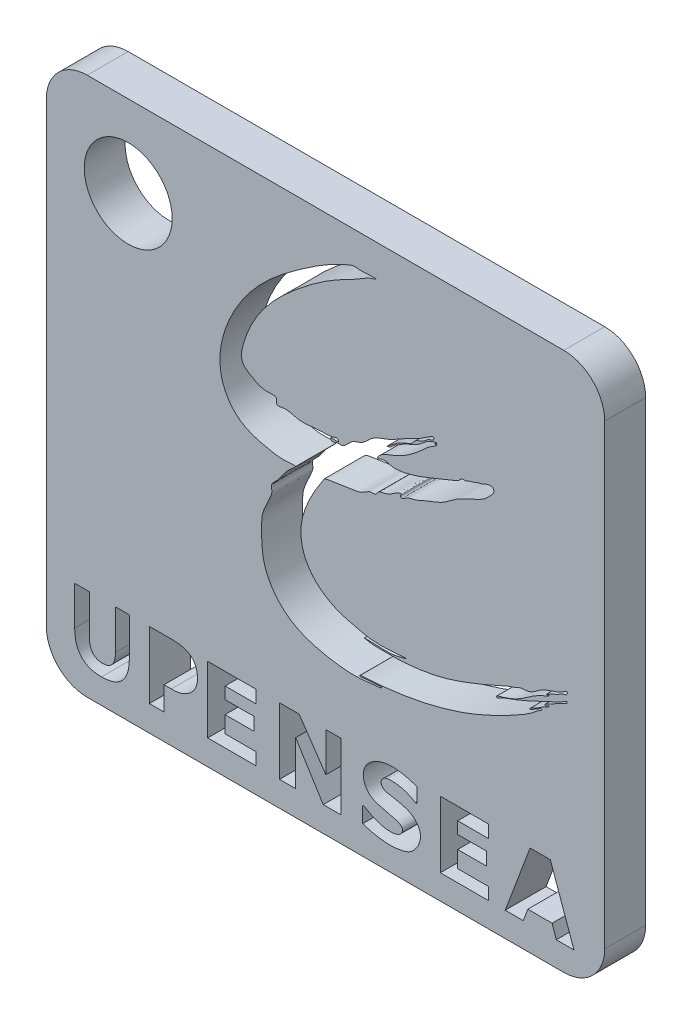
from build123d import *

# Parameters (mm, degrees)
ESQUISSE1_W             = 136.4195894
ESQUISSE1_H             = 131.62408288
ESQUISSE1_R             = 10.743118226
BOSS_EXTRU_1_DEPTH      = 10
CONG_1_R                = 10
ENL_V_MAT_EXTRU_1_DEPTH = 10
ESQUISSE3_W             = 7.085485745
ESQUISSE3_H             = 7.710675664
ENL_V_MAT_EXTRU_2_DEPTH = 10


with BuildPart() as part:
    # Esquisse1 → Boss.-Extru.1 (new body)
    with BuildSketch(Plane.XY):
        with Locations((-52.353656292, 10.654936195)):
            Rectangle(ESQUISSE1_W, ESQUISSE1_H)
        with Locations((-100.563450992, 56.466977635)):
            Circle(ESQUISSE1_R, mode=Mode.SUBTRACT)
        Polygon((-81.142119991, -32.834154765), (-69.373577812, -32.834154765), (-69.373577812, -35.9209855), (-76.89772773, -35.9209855), (-76.89772773, -38.814889315), (-69.867445854, -38.814889315), (-69.867445854, -41.991744615), (-76.89772773, -41.991744615), (-76.89772773, -46.050417687), (-69.373577812, -46.050417687), (-69.373577812, -49.040016126), (-81.142119991, -49.040016126), align=None, mode=Mode.SUBTRACT)
        Polygon((-63.602729459, -32.834154765), (-58.791958965, -32.834154765), (-52.26774974, -42.390122526), (-52.26774974, -32.834154765), (-48.574180783, -32.834154765), (-48.574180783, -49.040016126), (-52.913297725, -49.040016126), (-59.643973187, -38.236108552), (-59.643973187, -49.040016126), (-63.602729459, -49.040016126), align=None, mode=Mode.SUBTRACT)
        Polygon((-24.317493797, -32.949952007), (-12.548951618, -32.949952007), (-12.548951618, -36.036782743), (-20.073101536, -36.036782743), (-20.073101536, -38.930686557), (-13.04281966, -38.930686557), (-13.04281966, -42.107541857), (-20.073101536, -42.107541857), (-20.073101536, -46.16621493), (-12.548951618, -46.16621493), (-12.548951618, -49.155813369), (-24.317493797, -49.155813369), align=None, mode=Mode.SUBTRACT)
        Polygon((-2.380831571, -32.949952007), (-8.462013051, -49.155813369), (-4.055348693, -49.155813369), (-2.933514422, -46.16621493), (3.00425704, -46.16621493), (4.031172801, -49.155813369), (8.341293256, -49.155813369), (2.56810439, -32.949952007), align=None, mode=Mode.SUBTRACT)
        with BuildLine():
            Line((-30.008433918, -33.75561302), (-30.008433918, -37.365831656))
            Line((-30.008433918, -37.365831656), (-30.440269707, -37.365831656))
            add(Edge.make_bspline(
                [(-30.440269707, -37.365831656), (-32.169583727, -36.213527846), (-34.676354356, -35.502213926), (-37.924591159, -35.675126943), (-39.003366848, -37.004461808), (-38.37222083, -38.542287073), (-36.202765447, -38.91668114), (-33.693450515, -39.313242217), (-30.724735473, -40.385038538), (-28.608765411, -43.337263363), (-29.678516982, -46.511417412), (-31.575182552, -48.552112258), (-36.158155654, -49.965655118), (-40.259045765, -49.248104373), (-43.266807199, -48.245335369)],
                knots=[0, 0, 0, 0, 0.152919806, 0.204126248, 0.234844966, 0.26786857, 0.309744694, 0.391869949, 0.468930864, 0.544718631, 0.643629321, 0.695196685, 0.754799141, 1, 1, 1, 1], degree=3))
            Line((-43.266807199, -48.245335369), (-43.266807199, -44.532632267))
            add(Edge.make_bspline(
                [(-30.008433918, -33.75561302), (-32.644971309, -32.896452561), (-37.113590856, -31.754708493), (-42.138335473, -34.399521694), (-43.535120697, -37.913361146), (-42.292785158, -41.310277563), (-39.021126972, -42.472622706), (-36.464431129, -43.059062316), (-34.542927456, -43.499377192), (-33.418874665, -44.394863071), (-33.663521479, -45.581320465), (-34.907541611, -46.47076973), (-37.020426645, -46.661102185), (-39.641294731, -46.097511522), (-41.6577397, -45.143903497), (-42.756878285, -44.40189889), (-43.233639361, -44.300144577), (-43.266807199, -44.532632267)],
                knots=[0, 0, 0, 0, 0.213304767, 0.332543217, 0.387996487, 0.489669263, 0.562609108, 0.640595189, 0.690512906, 0.712560948, 0.740191541, 0.766735411, 0.824594443, 0.89393054, 0.970764374, 0.987194069, 1, 1, 1, 1], degree=3))
        make_face(mode=Mode.SUBTRACT)
        with BuildLine():
            add(Edge.make_bspline(
                [(-52.652098306, 20.026232938), (-55.333372618, 15.951546601), (-60.248590149, 7.988655431), (-56.116195099, -2.777940026), (-49.946281098, -6.253055945), (-43.723461916, -7.72162828), (-40.621702469, -8.844280722), (-31.210742721, -7.710165563), (-35.493116, -8.795101319), (-37.2317032, -9.019742152), (-44.577859422, -8.479877777), (-40.323258198, -9.251510519), (-38.151832984, -9.105692656), (-34.404220219, -9.217654392), (-29.497752885, -8.775060499), (-20.833091405, -7.309102823), (-9.809231942, -2.324559127), (-7.156516295, -1.140457568), (-5.628572694, -0.695184894), (-4.904754201, -0.234145954), (-3.990585775, -0.127234677), (-1.951826247, -0.184893172), (-0.260390225, 1.941104173), (3.493517157, 3.019647609), (5.324434134, 3.851637777), (6.753202275, 4.830476683), (6.724273256, 3.743571363), (5.768096418, 3.792115374), (4.253624966, 2.744272758), (3.157086176, 2.485618687), (1.561867199, 1.596334357), (1.977135738, 1.473475355), (2.377175787, 1.857226451), (2.206656482, 1.559210408), (2.133610218, 1.43914648), (2.130359585, 1.43381815)],
                knots=[0, 0, 0, 0, 0.034118173, 0.050236448, 0.068967481, 0.073500141, 0.095563045, 0.104190877, 0.107921759, 0.116908237, 0.126964302, 0.130310205, 0.137621374, 0.144820214, 0.154992728, 0.171421939, 0.207781336, 0.216895984, 0.219190241, 0.229442387, 0.232264538, 0.246130236, 0.386672642, 0.489153724, 0.601852187, 0.608768219, 0.628383974, 0.656973958, 0.68694343, 0.800374789, 0.80697629, 0.814481946, 0.827884702, 0.837106078, 0.837535097, 0.837535097, 0.837535097, 0.837535097], degree=3))
            add(Edge.make_bspline(
                [(2.130359585, 1.43381815), (-3.214312707, -0.498346865), (-3.563570622, -3.157387472), (-10.743341226, -4.819635104), (-10.420691573, -5.261894124), (-10.007595864, -5.019058872), (-9.135455421, -4.479732982), (-6.292361876, -3.546240997), (-2.2056624, -1.834324596), (2.621682439, 0.573941447), (5.127431502, 1.623706987), (6.726831307, 2.693079718), (6.706094212, 2.036736565), (6.189160701, 2.034859656), (5.690310498, 1.522147044), (4.621032633, 1.243485475), (3.480178109, 0.383484411), (2.215050618, -0.129670901), (1.593513494, -0.54765074), (1.086875911, -0.791217949), (1.508743121, -1.116706582), (1.744119846, -0.768907877), (2.027873581, -0.552749762), (2.377821647, -0.803783239), (1.896463023, -0.876947829), (1.60969602, -1.186354944), (0.754377502, -1.490972386), (-0.268271543, -2.286818845), (-1.478114136, -2.935241057), (-2.253250704, -3.222407651), (-2.566940145, -3.628079858), (-1.759345713, -3.505969669), (-1.40453558, -2.961035139), (-0.376094191, -2.665079247), (0.024278531, -2.158664493), (0.517602005, -2.141735103), (0.384170616, -2.562307677), (-0.127266893, -2.644220198), (-0.721100511, -3.158620227), (-2.334135939, -4.566001366), (-7.470936071, -7.511184121), (-19.247832634, -13.45945851), (-32.514037748, -16.377973537), (-41.787654463, -17.009436609), (-43.63112071, -17.089519551), (-43.832012786, -17.127497424), (-44.081117005, -17.314863302), (-43.59839564, -17.483155109), (-43.064754329, -17.260311756), (-42.285692849, -17.304438318), (-41.992916699, -17.270656454)],
                knots=[0, 0, 0, 0, 0.134847579, 0.143034237, 0.144601639, 0.148638772, 0.154180377, 0.178067515, 0.234677611, 0.292201023, 0.330745501, 0.333193175, 0.337239427, 0.34163035, 0.346584802, 0.358071859, 0.373748347, 0.389768442, 0.396912852, 0.399366253, 0.402749079, 0.40598643, 0.410304005, 0.412055835, 0.415102654, 0.419095224, 0.426513149, 0.440578697, 0.458947906, 0.465949143, 0.46750081, 0.470952025, 0.480463688, 0.491216585, 0.499184075, 0.500837468, 0.502285256, 0.509315764, 0.515195501, 0.525664095, 0.573905162, 0.691976912, 0.92332858, 0.972552013, 0.974530944, 0.977935359, 0.979470166, 0.981332426, 0.988581693, 1, 1, 1, 1], degree=3))
            add(Edge.make_bspline(
                [(-41.992916699, -17.270656454), (-41.978770433, -17.283671019), (-39.842833153, -17.180995975), (-38.754972142, -16.972927034), (-38.56627859, -17.069596074), (-38.697489549, -17.357079011), (-38.810607256, -17.342776782), (-38.990908075, -17.342776782)],
                knots=[0, 0, 0, 0, 0.789100761, 0.825841685, 0.866784773, 0.917493908, 1, 1, 1, 1], degree=3))
            add(Edge.make_bspline(
                [(-38.990908075, -17.342776782), (-41.407201958, -17.62983322), (-45.255220147, -18.158589845), (-52.834136232, -17.194088447), (-61.399430635, -15.155735742), (-68.033075329, -6.433305832), (-67.963920163, 0.273955902), (-67.947755656, 5.785975734), (-66.071472293, 8.633756763), (-65.318436127, 11.156463499), (-65.874789922, 12.393013974), (-64.105117087, 13.819844713), (-62.677337444, 15.98133093), (-61.473504174, 17.588750465), (-59.105921877, 19.390616858), (-63.266642115, 18.86420507), (-66.46854125, 19.584980474), (-72.926779768, 21.049765847), (-80.975118799, 30.535918056), (-74.112985885, 49.437680233), (-60.005635124, 60.732893126), (-50.392435567, 66.872912063), (-45.553455597, 68.719935846), (-44.236080492, 68.540864423), (-42.743505943, 68.5662796), (-38.909293603, 68.841278504), (-41.956114989, 67.996446056), (-44.303088817, 66.325677382), (-50.048941716, 63.638621493), (-58.096812183, 58.152601772), (-67.146252995, 50.111130884), (-71.802562316, 41.728184834), (-73.49277894, 34.616304496), (-69.773211333, 32.427232418), (-67.601158187, 31.192428245), (-64.226385985, 31.721223638), (-64.392532215, 30.572013101), (-64.279416292, 29.606591775), (-61.714357163, 30.433432523), (-58.805473303, 28.892813781), (-54.27163819, 29.906056056), (-51.304533431, 29.524580882), (-49.431265296, 30.360855222), (-48.900037177, 29.444687488), (-50.12989106, 29.540716306), (-51.490492181, 29.528280972), (-50.557826929, 28.62164321), (-49.637000925, 29.385630938), (-47.691473516, 28.95383553), (-46.367374706, 31.579993033), (-43.254609252, 31.977553237), (-40.892666049, 35.077401503), (-36.496613502, 36.056273401), (-31.986428512, 39.187122499), (-29.468647676, 39.894578423), (-25.689328969, 42.743208011), (-25.998133858, 41.291168476), (-27.090892458, 41.314477403), (-27.976084067, 40.3732572), (-29.141035611, 39.749769228), (-30.482997724, 39.309731113), (-31.30778381, 37.995348084), (-33.158844646, 37.483890908), (-35.084473287, 36.39052848), (-36.06055345, 35.467780085), (-37.801105233, 34.347030916), (-36.187276168, 34.900876735), (-35.6811919, 35.644074414), (-34.210089591, 36.427430941), (-32.883056366, 37.412172576), (-30.967521068, 38.004672181), (-28.505558164, 39.456709964), (-27.390683651, 41.017116254), (-25.003529766, 41.394984385), (-25.326448713, 41.029864469), (-25.333108726, 41.116084225), (-25.636809681, 40.976318507)],
                knots=[0, 0, 0, 0, 0.026687041, 0.041758511, 0.083493474, 0.118973002, 0.150540371, 0.156597534, 0.176994959, 0.18017269, 0.185825157, 0.191479594, 0.201603433, 0.213817923, 0.218106659, 0.223795932, 0.242243458, 0.266099554, 0.288781538, 0.369710272, 0.440444573, 0.490023006, 0.491708173, 0.496504241, 0.503315345, 0.512757585, 0.517466541, 0.527117388, 0.549027526, 0.582504712, 0.63508691, 0.675369094, 0.692163791, 0.702025976, 0.717110337, 0.724426756, 0.726291893, 0.728748425, 0.733278045, 0.748050913, 0.765920834, 0.779574845, 0.782783307, 0.784336954, 0.788151912, 0.791966871, 0.79347413, 0.798862712, 0.802060091, 0.813838189, 0.823241002, 0.834393423, 0.85328146, 0.871386034, 0.888313364, 0.896675766, 0.89777436, 0.902184864, 0.905808952, 0.91165869, 0.916425933, 0.920642695, 0.927542642, 0.936656222, 0.942844494, 0.946607064, 0.949757772, 0.954208113, 0.957935126, 0.967061389, 0.972245786, 0.979627044, 0.996876113, 0.997505843, 0.998262685, 1, 1, 1, 1], degree=3))
            add(Edge.make_bspline(
                [(-25.636809681, 40.976318507), (-25.673258333, 40.805376364), (-25.424215441, 40.938010465), (-25.065821032, 40.905062014), (-25.439614942, 40.584427304), (-25.874651688, 40.301134124), (-26.941552919, 39.715328918), (-28.329068854, 38.402753262), (-31.096316177, 35.997162007), (-34.738526255, 33.496217248), (-38.853959561, 32.451320789), (-39.612196442, 31.096044529), (-39.717797356, 30.920959872), (-39.261760906, 30.81291606), (-38.928019871, 31.140425036), (-38.144931858, 31.235695), (-37.279676464, 31.288368851), (-36.20014798, 30.887486555), (-34.999079387, 30.796486673), (-32.300733642, 31.184297248), (-28.877540848, 32.266622968), (-24.619151651, 34.065696336), (-21.607421775, 35.232391018), (-19.640293695, 36.104843266), (-19.110753486, 36.974270634), (-18.14019836, 36.731030004), (-17.316633066, 37.269642577), (-16.154401145, 37.475458111), (-15.208827238, 37.996418501), (-14.049456585, 38.13195807), (-13.21108948, 38.69552564), (-12.300764677, 38.898387228), (-11.355762242, 38.847899213), (-11.085421566, 37.822252303), (-11.995629862, 36.813479717), (-13.394968388, 35.2513936), (-16.581143506, 33.72258403), (-20.33311743, 32.158132947), (-23.773899201, 29.142102975), (-27.354984806, 28.126261185), (-30.337552866, 26.509514021), (-32.261349636, 26.435819054), (-33.787517076, 25.051958539), (-34.135189926, 25.825361506), (-33.539448873, 26.428661403), (-34.870912277, 25.978588293), (-35.528112864, 25.52914919), (-36.740952316, 24.668307304), (-38.113188297, 24.268809302), (-39.527513629, 24.011071615), (-40.004680712, 22.786271955), (-41.133762343, 23.043587392), (-42.307102186, 22.505250346), (-43.784678722, 21.379099809), (-46.362204813, 21.215026588), (-49.340221818, 20.518310534), (-51.523631759, 20.46007552), (-52.652098306, 20.026232938)],
                knots=[0, 0, 0, 0, 0.003834771, 0.005625769, 0.008650413, 0.013337213, 0.025484996, 0.043793879, 0.074034413, 0.138519412, 0.186487406, 0.188035725, 0.189270321, 0.191768902, 0.197818485, 0.204073543, 0.21530722, 0.224788642, 0.239449454, 0.252378597, 0.309642938, 0.350812124, 0.396294991, 0.411558776, 0.416284588, 0.425569842, 0.43728448, 0.446181137, 0.462020104, 0.470349452, 0.482049517, 0.492444261, 0.500051468, 0.507957674, 0.519114075, 0.539936082, 0.57420713, 0.626741522, 0.66709193, 0.713692614, 0.742757768, 0.767935224, 0.78126626, 0.7848311, 0.790075173, 0.797680908, 0.809788701, 0.82317486, 0.840569523, 0.856115471, 0.863527385, 0.876385841, 0.884884293, 0.903946939, 0.932867387, 0.962688937, 1, 1, 1, 1], degree=3))
        make_face(mode=Mode.SUBTRACT)
    extrude(amount=BOSS_EXTRU_1_DEPTH)

    # Congé1
    cong_1_edges = [part.edges().sort_by_distance(p)[0] for p in [
        (15.856138408, -55.157105245, 5),
        (-120.563450992, -55.157105245, 5),
        (-120.563450992, 76.466977635, 5),
        (15.856138408, 76.466977635, 5),
    ]]
    fillet(cong_1_edges, radius=CONG_1_R)

    # Esquisse2 → Enlèv. mat.-Extru.1 (cut)
    with BuildSketch(Plane.XY.offset(10)):
        with BuildLine():
            add(Edge.make_bspline(
                [(-100.291015912, -41.824360581), (-100.296636772, -42.118021123), (-100.307521918, -42.686712998), (-100.384260861, -43.512818623), (-100.517893264, -44.281284117), (-100.699001882, -44.995841289), (-100.93796449, -45.65212286), (-101.233225955, -46.25053387), (-101.573834101, -46.797442716), (-101.976624194, -47.282627315), (-102.429648857, -47.713049526), (-102.940113879, -48.081372564), (-103.499353822, -48.3983016), (-104.114609105, -48.652185303), (-104.780454362, -48.852426698), (-105.500175226, -48.988075106), (-106.270732686, -49.078824167), (-106.802727292, -49.087785244), (-107.076802733, -49.092401854)],
                knots=[0, 0, 0, 0, 0.000880948, 0.001706011, 0.002486066, 0.003218813, 0.003914726, 0.004577058, 0.005217536, 0.005842973, 0.006463632, 0.007087202, 0.007726667, 0.008387703, 0.009079683, 0.009808854, 0.010582272, 0.011404138, 0.011404138, 0.011404138, 0.011404138], degree=3))
            add(Edge.make_bspline(
                [(-107.076802733, -49.092401854), (-107.341512969, -49.087431031), (-107.855746966, -49.077774561), (-108.60067959, -48.991758424), (-109.29584386, -48.857282599), (-109.939746707, -48.665225747), (-110.532886578, -48.415571022), (-111.073806461, -48.109706458), (-111.56585288, -47.749370651), (-112.002303671, -47.328674335), (-112.391984938, -46.856082362), (-112.725126312, -46.326125838), (-113.006823009, -45.741391255), (-113.234810289, -45.101453376), (-113.416152201, -44.407266502), (-113.540213389, -43.657425351), (-113.620110645, -42.853868796), (-113.62819132, -42.299557945), (-113.632351946, -42.014151042)],
                knots=[0, 0, 0, 0, 0.00079388, 0.001542216, 0.002246364, 0.002915696, 0.003554244, 0.004172865, 0.004775859, 0.005378813, 0.005986732, 0.006609073, 0.007251965, 0.007930069, 0.008643966, 0.0094015, 0.01020798, 0.011063955, 0.011063955, 0.011063955, 0.011063955], degree=3))
            Line((-113.632351946, -42.014151042), (-113.632351946, -32.565075124))
            Line((-113.632351946, -32.565075124), (-110.048112415, -32.565075124))
            Line((-110.048112415, -32.565075124), (-110.048112415, -42.042152914))
            add(Edge.make_bspline(
                [(-110.048112415, -42.042152914), (-110.045920191, -42.20610018), (-110.041668412, -42.524072922), (-110.003365312, -42.985303051), (-109.944198204, -43.415399791), (-109.85153235, -43.812822411), (-109.742223544, -44.180260936), (-109.605354575, -44.516833632), (-109.440119441, -44.818592974), (-109.251703991, -45.091140841), (-109.037279352, -45.330304564), (-108.797724392, -45.539558424), (-108.531213258, -45.713992902), (-108.240411352, -45.857073467), (-107.925371397, -45.970263663), (-107.585284115, -46.05061853), (-107.219143446, -46.097092664), (-106.967004989, -46.102666675), (-106.837231168, -46.105535577)],
                knots=[0, 0, 0, 0, 0.000491746, 0.000953732, 0.00138758, 0.001792888, 0.00217673, 0.002536689, 0.002880599, 0.003206858, 0.003528545, 0.003841723, 0.004158421, 0.004481235, 0.004811914, 0.005160562, 0.005527566, 0.005916792, 0.005916792, 0.005916792, 0.005916792], degree=3))
            add(Edge.make_bspline(
                [(-106.837231168, -46.105535577), (-106.709491757, -46.102843261), (-106.46140891, -46.097614509), (-106.102430017, -46.048836126), (-105.765604806, -45.976627334), (-105.455212124, -45.866883219), (-105.167970591, -45.730037061), (-104.907593922, -45.559346962), (-104.669045092, -45.36097067), (-104.460919026, -45.126419004), (-104.271309353, -44.868104978), (-104.113076459, -44.573691829), (-103.977083602, -44.250679805), (-103.864441072, -43.89791258), (-103.782260104, -43.514105109), (-103.720135105, -43.100637359), (-103.682835024, -42.655763681), (-103.678408377, -42.349208123), (-103.676131025, -42.191496228)],
                knots=[0, 0, 0, 0, 0.000383008, 0.000743841, 0.001085024, 0.001414662, 0.001729152, 0.002037235, 0.002346369, 0.002656956, 0.002975604, 0.00330561, 0.003656955, 0.004025944, 0.00441471, 0.004833168, 0.00527965, 0.005752735, 0.005752735, 0.005752735, 0.005752735], degree=3))
            Line((-103.676131025, -42.191496228), (-103.676131025, -32.565075124))
            Line((-103.676131025, -32.565075124), (-100.291015912, -32.565075124))
            Line((-100.291015912, -32.565075124), (-100.291015912, -41.824360581))
        make_face()
        with BuildLine():
            Line((-91.808315687, -43.118669301), (-91.808315687, -48.893277435))
            Line((-91.808315687, -48.893277435), (-95.392555218, -48.893277435))
            Line((-95.392555218, -48.893277435), (-95.392555218, -32.565075124))
            Line((-95.392555218, -32.565075124), (-89.754845122, -32.565075124))
            add(Edge.make_bspline(
                [(-89.754845122, -32.565075124), (-89.507852009, -32.567776719), (-89.029610782, -32.573007691), (-88.33671185, -32.638211956), (-87.69053189, -32.73477931), (-87.090986449, -32.874488042), (-86.538002215, -33.053051091), (-86.034411157, -33.275738225), (-85.575035896, -33.532141779), (-85.168846125, -33.83737508), (-84.806962874, -34.178333352), (-84.493216896, -34.560332207), (-84.230618613, -34.984896624), (-84.015498103, -35.448884309), (-83.846683202, -35.952722658), (-83.730890657, -36.497641057), (-83.658104779, -37.080745736), (-83.648929458, -37.482809074), (-83.644214531, -37.68941758)],
                knots=[0, 0, 0, 0, 0.000740729, 0.001434239, 0.002085933, 0.002699494, 0.00327901, 0.003826478, 0.004349004, 0.004853661, 0.005346646, 0.005837446, 0.006332146, 0.006840206, 0.007368554, 0.007922683, 0.008508884, 0.009128536, 0.009128536, 0.009128536, 0.009128536], degree=3))
            add(Edge.make_bspline(
                [(-83.644214531, -37.68941758), (-83.649056493, -37.891990935), (-83.658539487, -38.288731324), (-83.748665289, -38.867520269), (-83.891595697, -39.416288919), (-84.090374584, -39.934861747), (-84.34862126, -40.422487036), (-84.663783288, -40.87802952), (-85.038883931, -41.301641077), (-85.466109223, -41.689502214), (-85.933800974, -42.039687434), (-86.434418722, -42.344314639), (-86.965409749, -42.594771043), (-87.522505157, -42.802966723), (-88.109446602, -42.957552348), (-88.725713286, -43.063008601), (-89.370023954, -43.119332111), (-89.808672615, -43.118892745), (-90.031752516, -43.118669301)],
                knots=[0, 0, 0, 0, 0.000607353, 0.001189502, 0.001752479, 0.002306014, 0.002851596, 0.00340395, 0.003963866, 0.004545275, 0.00513207, 0.005714219, 0.006300115, 0.006890774, 0.007496035, 0.008118027, 0.0087645, 0.009433499, 0.009433499, 0.009433499, 0.009433499], degree=3))
            Line((-90.031752516, -43.118669301), (-91.808315687, -43.118669301))
        make_face()
        with BuildLine():
            Line((-91.901655258, -35.153692564), (-91.901655258, -40.530051861))
            Line((-91.901655258, -40.530051861), (-90.361552334, -40.530051861))
            add(Edge.make_bspline(
                [(-90.361552334, -40.530051861), (-90.234921274, -40.52900032), (-89.989449184, -40.526961925), (-89.634286944, -40.490240951), (-89.302163232, -40.439345407), (-88.995436207, -40.364591008), (-88.710838929, -40.272266478), (-88.453898726, -40.153868787), (-88.218750981, -40.016119255), (-88.010940744, -39.853711308), (-87.825599093, -39.67248844), (-87.664566841, -39.469921614), (-87.526542577, -39.246182834), (-87.420007416, -38.997556077), (-87.329878362, -38.732027325), (-87.274122361, -38.443120503), (-87.234664192, -38.13438975), (-87.230566259, -37.920832665), (-87.228454063, -37.810759022)],
                knots=[0, 0, 0, 0, 0.000379696, 0.000736033, 0.001070048, 0.00138699, 0.001682156, 0.001966173, 0.002234036, 0.002497912, 0.002755325, 0.003009941, 0.003272474, 0.003541311, 0.003819752, 0.004112034, 0.004422309, 0.004752344, 0.004752344, 0.004752344, 0.004752344], degree=3))
            add(Edge.make_bspline(
                [(-87.228454063, -37.810759022), (-87.230646631, -37.703811456), (-87.234918217, -37.495454929), (-87.2736179, -37.193746741), (-87.331644372, -36.911085184), (-87.414403726, -36.649507125), (-87.525057025, -36.409675889), (-87.659515134, -36.190103998), (-87.818633255, -35.990798101), (-88.000635308, -35.81115201), (-88.20792643, -35.65460912), (-88.440824954, -35.521090684), (-88.696760661, -35.405308555), (-88.977540097, -35.312873945), (-89.28180748, -35.242120552), (-89.609136859, -35.189136219), (-89.961657062, -35.157975912), (-90.20488545, -35.155150851), (-90.330439144, -35.153692564)],
                knots=[0, 0, 0, 0, 0.000320707, 0.000624806, 0.000910997, 0.001185517, 0.001445847, 0.001701449, 0.001956064, 0.002209078, 0.002466698, 0.002732984, 0.003012882, 0.003308047, 0.003618213, 0.003949156, 0.004302109, 0.004678694, 0.004678694, 0.004678694, 0.004678694], degree=3))
            Line((-90.330439144, -35.153692564), (-91.901655258, -35.153692564))
        make_face(mode=Mode.SUBTRACT)
    extrude(amount=-ENL_V_MAT_EXTRU_1_DEPTH, mode=Mode.SUBTRACT)

    # Esquisse3 → Enlèv. mat.-Extru.2 (cut)
    with BuildSketch(Plane.XY.offset(10)):
        with Locations((-90.088822121, -37.800032315)):
            Rectangle(ESQUISSE3_W, ESQUISSE3_H)
    extrude(amount=-ENL_V_MAT_EXTRU_2_DEPTH, mode=Mode.SUBTRACT)


solid = part.part
